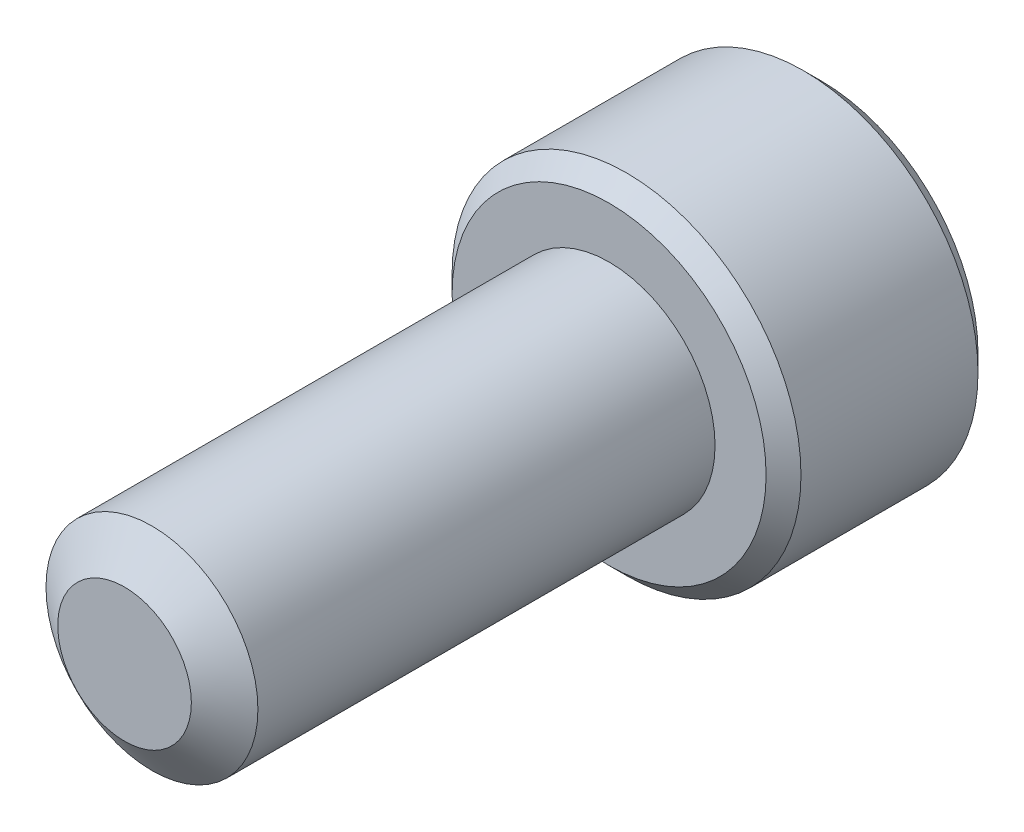
from build123d import *

# Parameters (mm, degrees)
SKETCH1_R          = 2.0828
EXTRUDE1_DEPTH     = 9.525
SKETCH6_R          = 3.429
EXTRUDE2_DEPTH     = 4.1656
CUT_EXTRUDE1_DEPTH = 2.67890625
CHAMFER1_SIZE      = 0.3429


with BuildPart() as part:
    # Sketch1 → Extrude1 (new body)
    with BuildSketch(Plane.XY):
        Circle(SKETCH1_R)
    extrude(amount=-EXTRUDE1_DEPTH)

    # Sketch4 → Cut-Revolve1 (revolve, cut)
    with BuildSketch(Plane(origin=(0, 0, 0), x_dir=(0, 0, -1), z_dir=(1, 0, 0))):
        Polygon((0.538848736, 2.0828), (0, 1.313244252), (0, 2.0828), align=None)
    revolve(axis=Axis((0, 0, 0), (0, 0, -1)), mode=Mode.SUBTRACT)

    # Sketch6 → Extrude2 (add)
    with BuildSketch(Plane(origin=(0, 0, -9.525), x_dir=(-1, 0, 0), z_dir=(0, 0, -1))):
        Circle(SKETCH6_R)
    extrude(amount=EXTRUDE2_DEPTH)

    # Sketch7 → Cut-Extrude1 (cut)
    with BuildSketch(Plane(origin=(0, 0, -13.6906), x_dir=(-1, 0, 0), z_dir=(0, 0, -1))):
        Polygon((0, 2.062222993), (-1.7859375, 1.031111496), (-1.7859375, -1.031111496), (0, -2.062222993), (1.7859375, -1.031111496), (1.7859375, 1.031111496), align=None)
    extrude(amount=-CUT_EXTRUDE1_DEPTH, mode=Mode.SUBTRACT)

    # Cut-Extrude2 cone 1 section (through the dimple's axis) → Cut-Extrude2 (revolve, cut)
    with BuildSketch(Plane(origin=(0, 0, -13.6906), x_dir=(0, 1, 0), z_dir=(1, 0, 0))):
        Polygon((0, 0), (2.062222993, 0), (0, 2.062222993), align=None)
    revolve(axis=Axis((0, 0, -13.6906), (0, 0, 1)), mode=Mode.SUBTRACT)

    # Chamfer1
    chamfer1_edges = [part.edges().sort_by_distance(p)[0] for p in [
        (3.429, 0, -13.6906),
        (3.429, 0, -9.525),
    ]]
    chamfer(chamfer1_edges, length=CHAMFER1_SIZE)


solid = part.part
